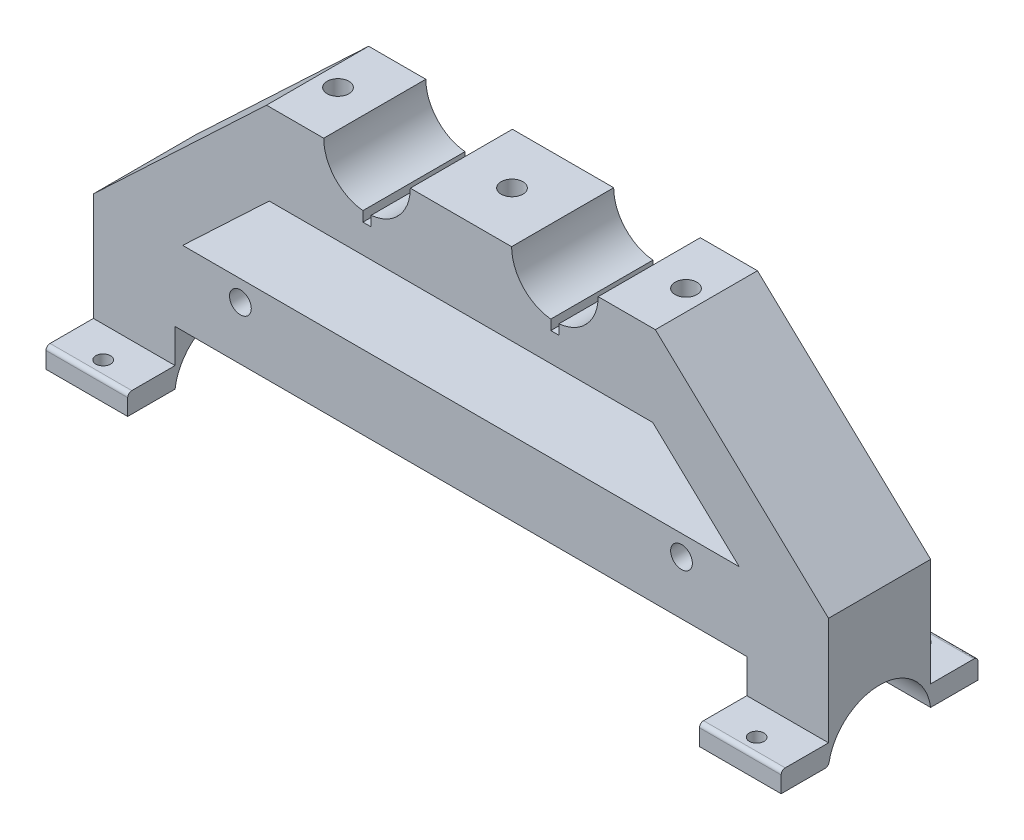
from build123d import *

# Parameters (mm, degrees)
BOSS_EXTRUDE1_DEPTH = 50.8
SKETCH7_W           = 228.6
SKETCH7_H           = 152.4
CUT_EXTRUDE5_DEPTH  = 19.05
SKETCH9_R           = 3.3782
CUT_EXTRUDE7_DEPTH  = 27.94
CUT_EXTRUDE8_DEPTH  = 40.64
SKETCH12_W          = 1.27
SKETCH12_H          = 31.75
CUT_EXTRUDE9_DEPTH  = 16.51
CUT_EXTRUDE10_REACH = 33.75
SKETCH13_R          = 3.3782
CUT_EXTRUDE11_DEPTH = 32.75
SKETCH15_R          = 16.002
CUT_EXTRUDE12_DEPTH = 229.6
SKETCH16_W          = 25.4
SKETCH16_H          = 6.35
BOSS_EXTRUDE2_DEPTH = 14.732
SKETCH17_W          = 25.4
SKETCH17_H          = 6.35
BOSS_EXTRUDE3_DEPTH = 14.732
FILLET7_R           = 1.27
FILLET8_R           = 1.27
FILLET9_R           = 1.27
FILLET10_R          = 1.27
CUT_EXTRUDE14_DEPTH = 47.482
FILLET15_R          = 1.27
SKETCH22_R          = 2.286
CUT_EXTRUDE15_DEPTH = 91.697941601


with BuildPart() as part:
    # Sketch2 → Boss-Extrude1 (new body)
    with BuildSketch(Plane.XY):
        with BuildLine():
            Line((215.9, 0), (228.6, 0))
            Line((228.6, 0), (228.6, 101.6))
            Line((228.6, 101.6), (174.752, 152.4))
            Line((174.752, 152.4), (156.972, 152.4))
            ThreePointArc((156.972, 152.4), (143.51, 138.938), (130.048, 152.4))
            Line((130.048, 152.4), (98.552, 152.4))
            ThreePointArc((98.552, 152.4), (85.09, 138.938), (71.628, 152.4))
            Line((71.628, 152.4), (53.848, 152.4))
            Line((53.848, 152.4), (0, 101.6))
            Line((0, 101.6), (0, 0))
            Line((0, 0), (12.7, 0))
            Line((12.7, 0), (215.9, 0))
        make_face()
    extrude(amount=BOSS_EXTRUDE1_DEPTH)

    # Sketch7 → Cut-Extrude5 (cut)
    with BuildSketch(Plane.XY.offset(50.8)):
        with Locations((114.3, 76.2)):
            Rectangle(SKETCH7_W, SKETCH7_H)
    extrude(amount=-CUT_EXTRUDE5_DEPTH, mode=Mode.SUBTRACT)

    # Sketch9 → Cut-Extrude7 (cut)
    with BuildSketch(Plane(origin=(0, 152.4, 0), x_dir=(1, 0, 0), z_dir=(0, 1, 0))):
        with Locations((60.198, -15.875)):
            Circle(SKETCH9_R)
        with Locations((114.3, -15.875)):
            Circle(SKETCH9_R)
        with Locations((168.402, -15.875)):
            Circle(SKETCH9_R)
    extrude(amount=-CUT_EXTRUDE7_DEPTH, mode=Mode.SUBTRACT)

    # Sketch10 → Cut-Extrude8 (cut)
    with BuildSketch(Plane.XY.offset(31.75)):
        Polygon((27.760759157, 101.6), (54.684759157, 127), (173.915240843, 127), (200.839240843, 101.6), align=None)
    extrude(amount=-CUT_EXTRUDE8_DEPTH, mode=Mode.SUBTRACT)

    # Sketch12 → Cut-Extrude9 (cut)
    with BuildSketch(Plane(origin=(0, 152.4, 0), x_dir=(1, 0, 0), z_dir=(0, 1, 0))):
        with Locations((85.725, -15.875)):
            Rectangle(SKETCH12_W, SKETCH12_H)
        with Locations((84.455, -15.875)):
            Rectangle(SKETCH12_W, SKETCH12_H)
        Polygon((143.51, 0), (142.24, 0), (142.24, -31.75), (144.78, -31.75), (144.78, 0), align=None)
    extrude(amount=-CUT_EXTRUDE9_DEPTH, mode=Mode.SUBTRACT)

    # Sketch13 → Cut-Extrude10 (cut, up to next)
    with BuildSketch(Plane.XY.offset(31.75), mode=Mode.PRIVATE) as cut_extrude10_sk1:
        with Locations((45.72, 95.25)):
            Circle(SKETCH13_R)
    cut_extrude10_tool1 = extrude(cut_extrude10_sk1.sketch, amount=-CUT_EXTRUDE10_REACH, mode=Mode.PRIVATE) & part.part
    add(cut_extrude10_tool1.solids().sort_by_distance((45.72, 95.25, 31.75))[0], mode=Mode.SUBTRACT)
    # Sketch13 → Cut-Extrude10 (cut, up to next)
    with BuildSketch(Plane.XY.offset(31.75), mode=Mode.PRIVATE) as cut_extrude10_sk2:
        with Locations((182.88, 95.25)):
            Circle(SKETCH13_R)
    cut_extrude10_tool2 = extrude(cut_extrude10_sk2.sketch, amount=-CUT_EXTRUDE10_REACH, mode=Mode.PRIVATE) & part.part
    add(cut_extrude10_tool2.solids().sort_by_distance((182.88, 95.25, 31.75))[0], mode=Mode.SUBTRACT)

    # Sketch14 → Cut-Extrude11 (cut, through all)
    with BuildSketch(Plane(origin=(0, 0, 0), x_dir=(-1, 0, 0), z_dir=(0, 0, -1))):
        Polygon((-182.88, 59.69), (-228.6, 59.69), (-228.6, 0), (0, 0), (0, 59.69), align=None)
    extrude(amount=-CUT_EXTRUDE11_DEPTH, mode=Mode.SUBTRACT)

    # Sketch15 → Cut-Extrude12 (cut, through all)
    with BuildSketch(Plane(origin=(228.6, 0, 0), x_dir=(0, 0, -1), z_dir=(1, 0, 0))):
        with Locations((-15.875, 59.69)):
            Circle(SKETCH15_R)
    extrude(amount=-CUT_EXTRUDE12_DEPTH, mode=Mode.SUBTRACT)

    # Sketch16 → Boss-Extrude2 (add)
    with BuildSketch(Plane.XY.offset(31.75)):
        with Locations((215.9, 64.877058399)):
            Rectangle(SKETCH16_W, SKETCH16_H)
        with Locations((12.7, 64.877058399)):
            Rectangle(SKETCH16_W, SKETCH16_H)
    extrude(amount=BOSS_EXTRUDE2_DEPTH)

    # Sketch17 → Boss-Extrude3 (add)
    with BuildSketch(Plane(origin=(0, 0, 0), x_dir=(-1, 0, 0), z_dir=(0, 0, -1))):
        with Locations((-215.9, 64.877058399)):
            Rectangle(SKETCH17_W, SKETCH17_H)
        with Locations((-12.7, 64.877058399)):
            Rectangle(SKETCH17_W, SKETCH17_H)
    extrude(amount=BOSS_EXTRUDE3_DEPTH)

    # Fillet7
    fillet7_edges = [part.edges().sort_by_distance(p)[0] for p in [
        (215.9, 68.052058399, 46.482),
    ]]
    fillet(fillet7_edges, radius=FILLET7_R)

    # Fillet8
    fillet8_edges = [part.edges().sort_by_distance(p)[0] for p in [
        (215.9, 68.052058399, -14.732),
    ]]
    fillet(fillet8_edges, radius=FILLET8_R)

    # Fillet9
    fillet9_edges = [part.edges().sort_by_distance(p)[0] for p in [
        (12.7, 68.052058399, -14.732),
    ]]
    fillet(fillet9_edges, radius=FILLET9_R)

    # Fillet10
    fillet10_edges = [part.edges().sort_by_distance(p)[0] for p in [
        (12.7, 68.052058399, 46.482),
    ]]
    fillet(fillet10_edges, radius=FILLET10_R)

    # Sketch20 → Cut-Extrude14 (cut, through all)
    with BuildSketch(Plane.XY.offset(31.75)):
        Polygon((66.04, 61.702058399), (25.4, 61.702058399), (25.4, 78.590265292), (203.2, 78.590265292), (203.2, 61.702058399), (162.56, 61.702058399), align=None)
    extrude(amount=-CUT_EXTRUDE14_DEPTH, mode=Mode.SUBTRACT)

    # Fillet15
    fillet15_edges = [part.edges().sort_by_distance(p)[0] for p in [
        (215.9, 61.702058399, 31.75),
    ]]
    fillet(fillet15_edges, radius=FILLET15_R)

    # Sketch22 → Cut-Extrude15 (cut, through all)
    with BuildSketch(Plane.XZ.offset(-61.702058399)):
        with Locations((12.7, 41.402)):
            Circle(SKETCH22_R)
        with Locations((12.7, -9.652)):
            Circle(SKETCH22_R)
        with Locations((215.9, -9.652)):
            Circle(SKETCH22_R)
        with Locations((215.9, 41.402)):
            Circle(SKETCH22_R)
    extrude(amount=-CUT_EXTRUDE15_DEPTH, mode=Mode.SUBTRACT)


solid = part.part
